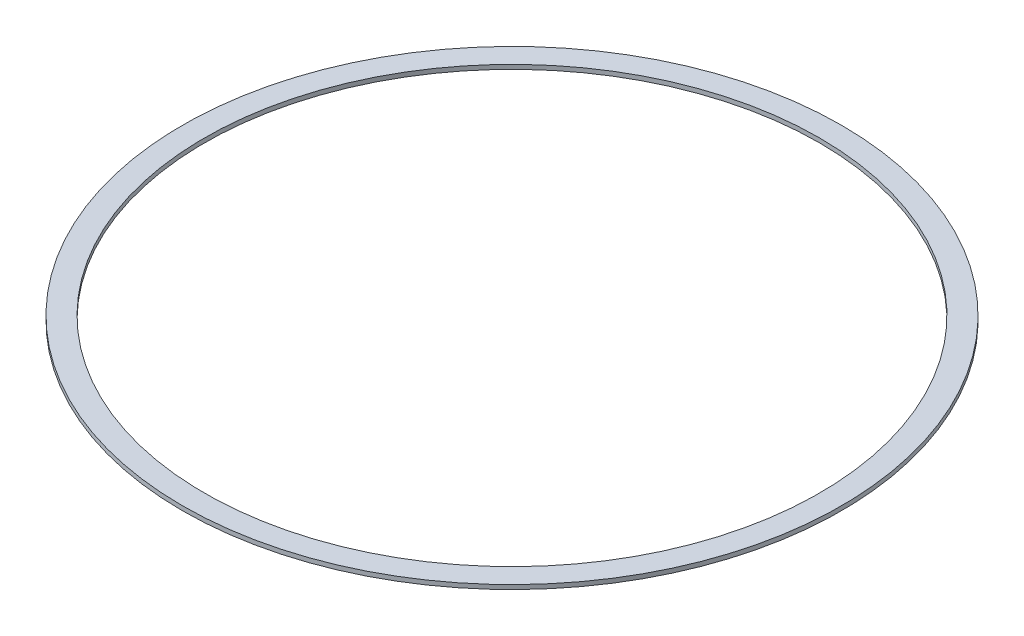
from build123d import *

# Parameters (mm, degrees)
SKETCH1_W = 5.08
SKETCH1_H = 1


with BuildPart() as part:
    # Sketch1 → Revolve1 (revolve)
    with BuildSketch(Plane.XY):
        with Locations((73.66, 22.934310161)):
            Rectangle(SKETCH1_W, SKETCH1_H)
    revolve(axis=Axis((0, 0, 0), (0, 1, 0)))


solid = part.part
